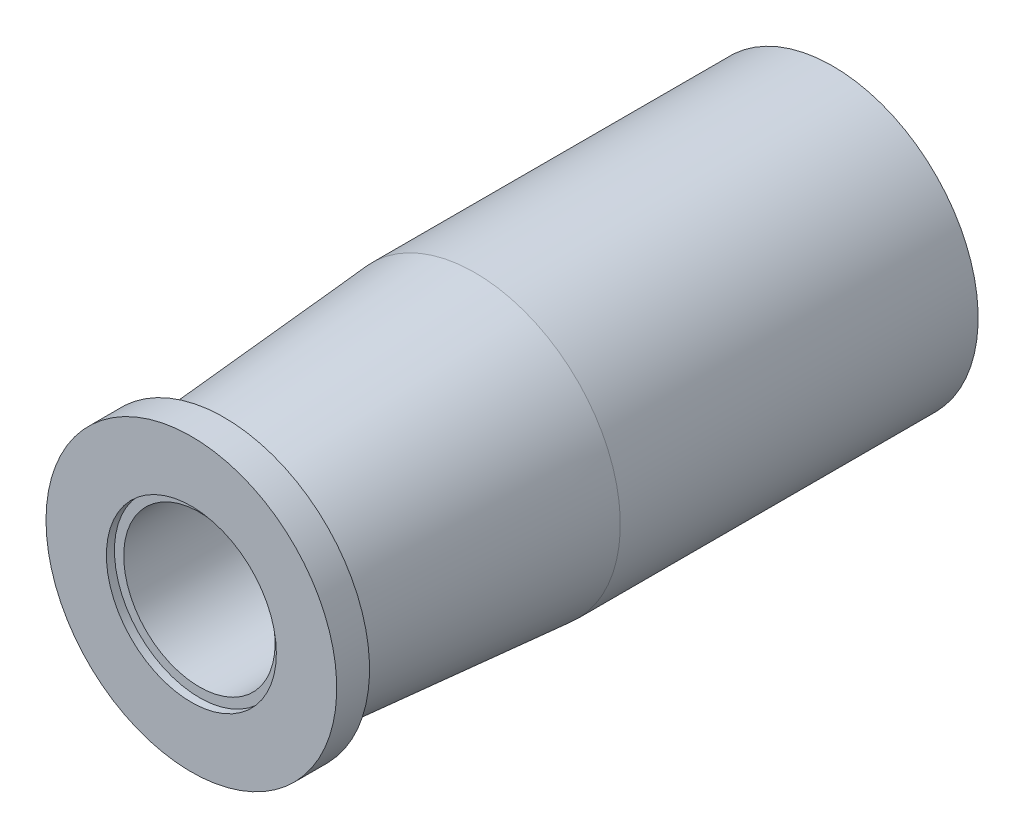
from build123d import *

# Parameters (mm, degrees)
SKETCH2_R          = 2.85
CUT_EXTRUDE1_DEPTH = 0.27
SKETCH3_R          = 2.539141962
CUT_EXTRUDE2_DEPTH = 5
SKETCH4_R          = 1.5
CUT_EXTRUDE3_DEPTH = 19


with BuildPart() as part:
    # Sketch1 → Revolve1 (revolve)
    with BuildSketch(Plane(origin=(0, 0, 0), x_dir=(1, 0, 0), z_dir=(0, 1, 0))):
        Polygon((0, 0), (-4.875, 0), (-4.875, 1.1), (-4.215, 1.1), (-4.875, 9.51), (-4.875, 21.51), (0, 21.51), align=None)
    revolve(axis=Axis((0, 0, -21.51), (0, 0, 1)))

    # Sketch2 → Cut-Extrude1 (cut)
    with BuildSketch(Plane.XY):
        Circle(SKETCH2_R)
    extrude(amount=-CUT_EXTRUDE1_DEPTH, mode=Mode.SUBTRACT)

    # Sketch3 → Cut-Extrude2 (cut)
    with BuildSketch(Plane.XY.offset(-0.27)):
        Circle(SKETCH3_R)
    extrude(amount=-CUT_EXTRUDE2_DEPTH, mode=Mode.SUBTRACT)

    # Sketch4 → Cut-Extrude3 (cut)
    with BuildSketch(Plane(origin=(0, 0, -21.51), x_dir=(-1, 0, 0), z_dir=(0, 0, -1))):
        Circle(SKETCH4_R)
    extrude(amount=-CUT_EXTRUDE3_DEPTH, mode=Mode.SUBTRACT)


solid = part.part
